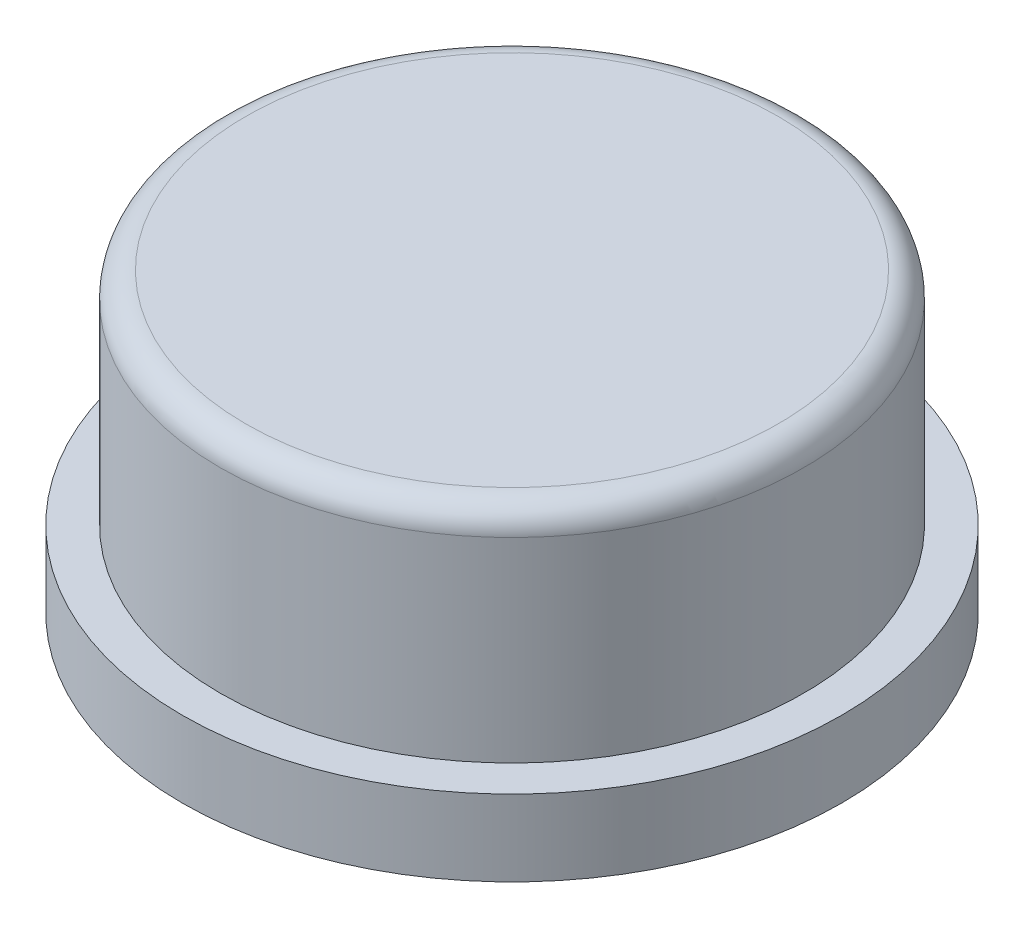
from build123d import *

# Parameters (mm, degrees)
SKETCH1_R           = 6.5
SKETCH1_R_2         = 5
BOSS_EXTRUDE1_DEPTH = 1.5
SKETCH2_R           = 5.75
SKETCH2_R_2         = 5
BOSS_EXTRUDE2_DEPTH = 4.35
FILLET1_R           = 0.5
SKETCH3_R           = 5
BOSS_EXTRUDE3_DEPTH = 4


with BuildPart() as part:
    # Sketch1 → Boss-Extrude1 (new body)
    with BuildSketch(Plane(origin=(0, 0, 0), x_dir=(1, 0, 0), z_dir=(0, 1, 0))):
        Circle(SKETCH1_R)
        Circle(SKETCH1_R_2, mode=Mode.SUBTRACT)
    extrude(amount=BOSS_EXTRUDE1_DEPTH)

    # Sketch2 → Boss-Extrude2 (add)
    with BuildSketch(Plane(origin=(0, 1.5, 0), x_dir=(1, 0, 0), z_dir=(0, 1, 0))):
        Circle(SKETCH2_R)
        Circle(SKETCH2_R_2, mode=Mode.SUBTRACT)
    extrude(amount=BOSS_EXTRUDE2_DEPTH)

    # Fillet1
    fillet1_edges = [part.edges().sort_by_distance(p)[0] for p in [
        (-5.75, 5.85, 0),
    ]]
    fillet(fillet1_edges, radius=FILLET1_R)

    # Sketch3 → Boss-Extrude3 (add)
    with BuildSketch(Plane(origin=(0, 5.85, 0), x_dir=(1, 0, 0), z_dir=(0, 1, 0))):
        Circle(SKETCH3_R)
    extrude(amount=-BOSS_EXTRUDE3_DEPTH)


solid = part.part
